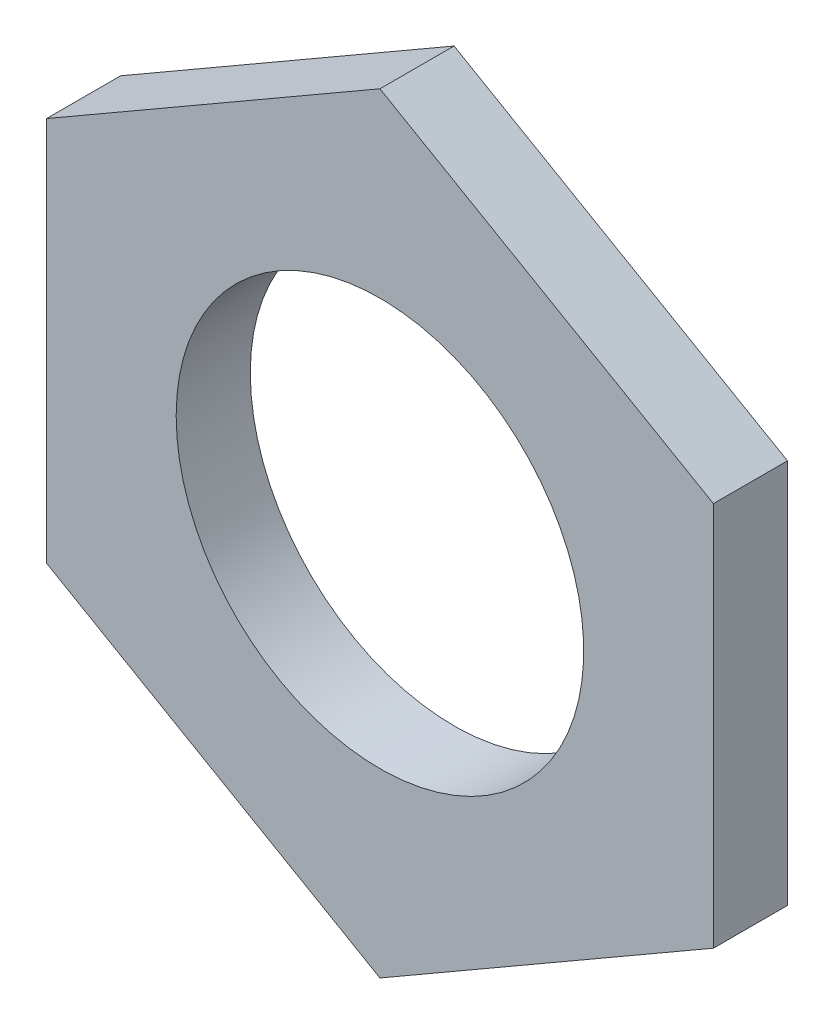
from build123d import *

# Parameters (mm, degrees)
BOSS_EXTRU_1_DEPTH                        = 3
TROU_POUR_TARAUDAGE_POUR_TROU_TARAUD_M1_D = 16.5


with BuildPart() as part:
    # Esquisse1 → Boss.-Extru.1 (new body)
    with BuildSketch(Plane.XY):
        Polygon((0, -15.588457268), (13.5, -7.794228634), (13.5, 7.794228634), (0, 15.588457268), (-13.5, 7.794228634), (-13.5, -7.794228634), align=None)
    extrude(amount=BOSS_EXTRU_1_DEPTH)

    # Trou pour taraudage pour trou taraudé M181 (through all)
    with Locations(Plane(origin=(0, 0, 0), x_dir=(-1, 0, 0), z_dir=(0, 0, -1))):
        with Locations((0, 0)):
            Hole(TROU_POUR_TARAUDAGE_POUR_TROU_TARAUD_M1_D / 2)


solid = part.part
